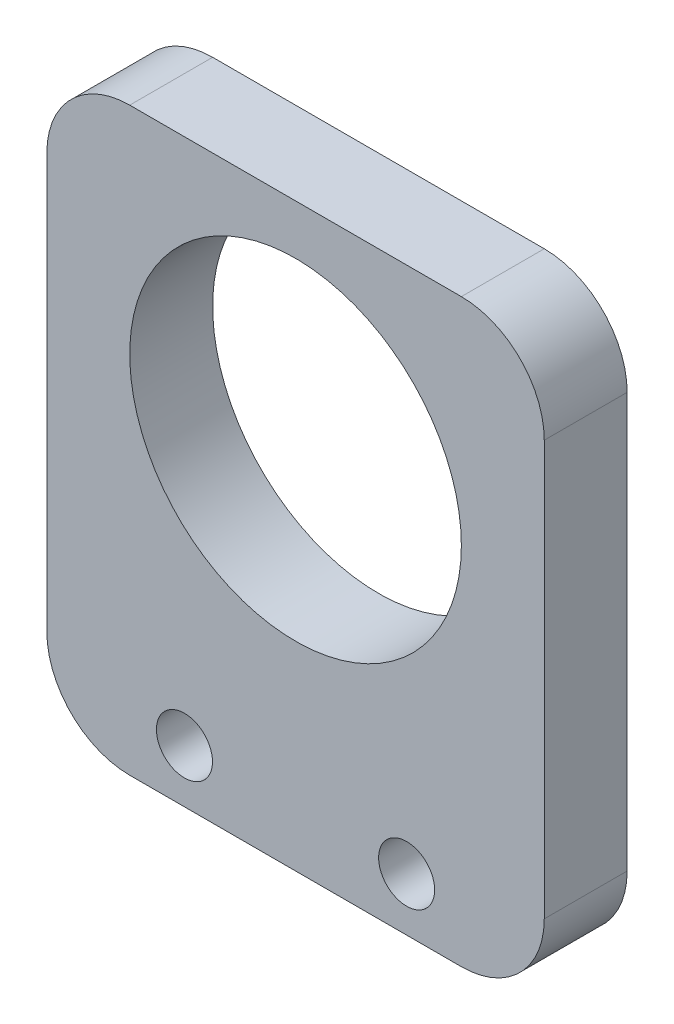
from build123d import *

# Parameters (mm, degrees)
SKETCH1_W           = 38.1
SKETCH1_H           = 44.45
SKETCH1_R           = 12.7
SKETCH1_R_2         = 2.1463
BOSS_EXTRUDE1_DEPTH = 6.35
FILLET1_R           = 6.35


with BuildPart() as part:
    # Sketch1 → Boss-Extrude1 (new body)
    with BuildSketch(Plane.XY):
        with Locations((0, 22.225)):
            Rectangle(SKETCH1_W, SKETCH1_H)
        with Locations((0, 27.94)):
            Circle(SKETCH1_R, mode=Mode.SUBTRACT)
        with Locations((8.509, 4.064)):
            Circle(SKETCH1_R_2, mode=Mode.SUBTRACT)
        with Locations((-8.509, 4.064)):
            Circle(SKETCH1_R_2, mode=Mode.SUBTRACT)
    extrude(amount=BOSS_EXTRUDE1_DEPTH)

    # Fillet1
    fillet1_edges = [part.edges().sort_by_distance(p)[0] for p in [
        (19.05, 0, 3.175),
        (-19.05, 0, 3.175),
        (-19.05, 44.45, 3.175),
        (19.05, 44.45, 3.175),
    ]]
    fillet(fillet1_edges, radius=FILLET1_R)


solid = part.part
